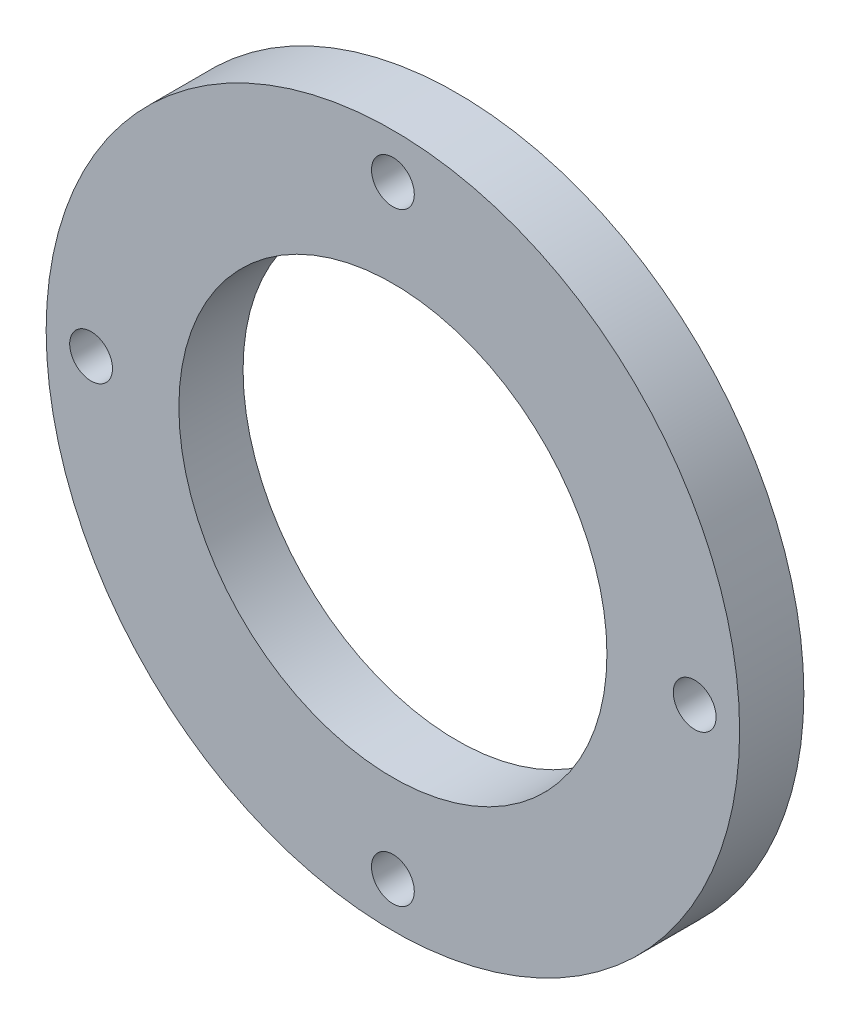
from build123d import *

# Parameters (mm, degrees)
CROQUIS1_R              = 81
CROQUIS1_R_2            = 50
SALIENTE_EXTRUIR1_DEPTH = 15
CROQUIS2_R              = 5
CORTAR_EXTRUIR1_DEPTH   = 15


with BuildPart() as part:
    # Croquis1 → Saliente-Extruir1 (new body)
    with BuildSketch(Plane.XY):
        Circle(CROQUIS1_R)
        Circle(CROQUIS1_R_2, mode=Mode.SUBTRACT)
    extrude(amount=SALIENTE_EXTRUIR1_DEPTH)

    # Croquis2 → Cortar-Extruir1 (cut)
    with BuildSketch(Plane.XY.offset(15)):
        with Locations((0, 70.5)):
            Circle(CROQUIS2_R)
        with Locations((-70.5, 0)):
            Circle(CROQUIS2_R)
        with Locations((70.5, 0)):
            Circle(CROQUIS2_R)
        with Locations((0, -70.5)):
            Circle(CROQUIS2_R)
    extrude(amount=-CORTAR_EXTRUIR1_DEPTH, mode=Mode.SUBTRACT)


solid = part.part
